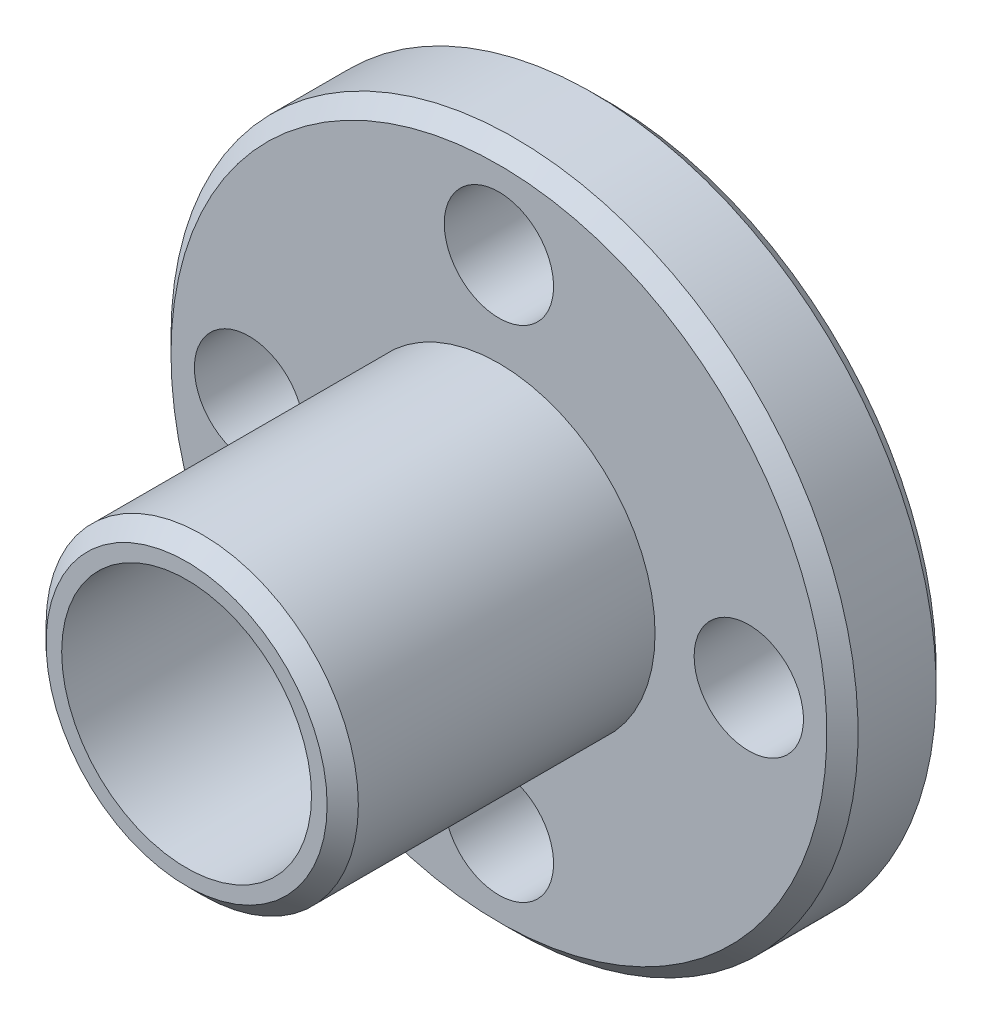
from build123d import *

# Parameters (mm, degrees)
SKETCH_1_R          = 5
EXTRUDE_1_DEPTH     = 7.5
EXTRUDE_START       = -1.5
SKETCH_2_R          = 11
EXTRUDE_2_DEPTH     = 3.5
SKETCH_3_R          = 4
CUT_EXTRUDE_1_DEPTH = 16
SKETCH_4_R          = 1.75
CUT_EXTRUDE_2_DEPTH = 14.5
CHAMFER_1_SIZE      = 0.5


with BuildPart() as part:
    # 草图1 → 凸台-拉伸1 (new body, symmetric)
    with BuildSketch(Plane.XY):
        Circle(SKETCH_1_R)
    extrude(amount=EXTRUDE_1_DEPTH, both=True)

    # 草图2 → 凸台-拉伸2 (add)
    with BuildSketch(Plane(origin=(0, 0, -7.5), x_dir=(-1, 0, 0), z_dir=(0, 0, -1)).offset(EXTRUDE_START)):
        Circle(SKETCH_2_R)
    extrude(amount=-EXTRUDE_2_DEPTH)

    # 草图3 → 切除-拉伸1 (cut, through all)
    with BuildSketch(Plane(origin=(0, 0, -7.5), x_dir=(-1, 0, 0), z_dir=(0, 0, -1))):
        Circle(SKETCH_3_R)
    extrude(amount=-CUT_EXTRUDE_1_DEPTH, mode=Mode.SUBTRACT)

    # 草图4 → 切除-拉伸2 (cut, through all)
    with BuildSketch(Plane(origin=(0, 0, -6), x_dir=(-1, 0, 0), z_dir=(0, 0, -1))):
        with Locations((0, 8)):
            Circle(SKETCH_4_R)
        with Locations((8, 0)):
            Circle(SKETCH_4_R)
        with Locations((0, -8)):
            Circle(SKETCH_4_R)
        with Locations((-8, 0)):
            Circle(SKETCH_4_R)
    extrude(amount=-CUT_EXTRUDE_2_DEPTH, mode=Mode.SUBTRACT)

    # 倒角1
    chamfer_1_edges = [part.edges().sort_by_distance(p)[0] for p in [
        (-5, 0, -7.5),
        (-5, 0, 7.5),
        (11, 0, -2.5),
        (11, 0, -6),
    ]]
    chamfer(chamfer_1_edges, length=CHAMFER_1_SIZE)


solid = part.part
